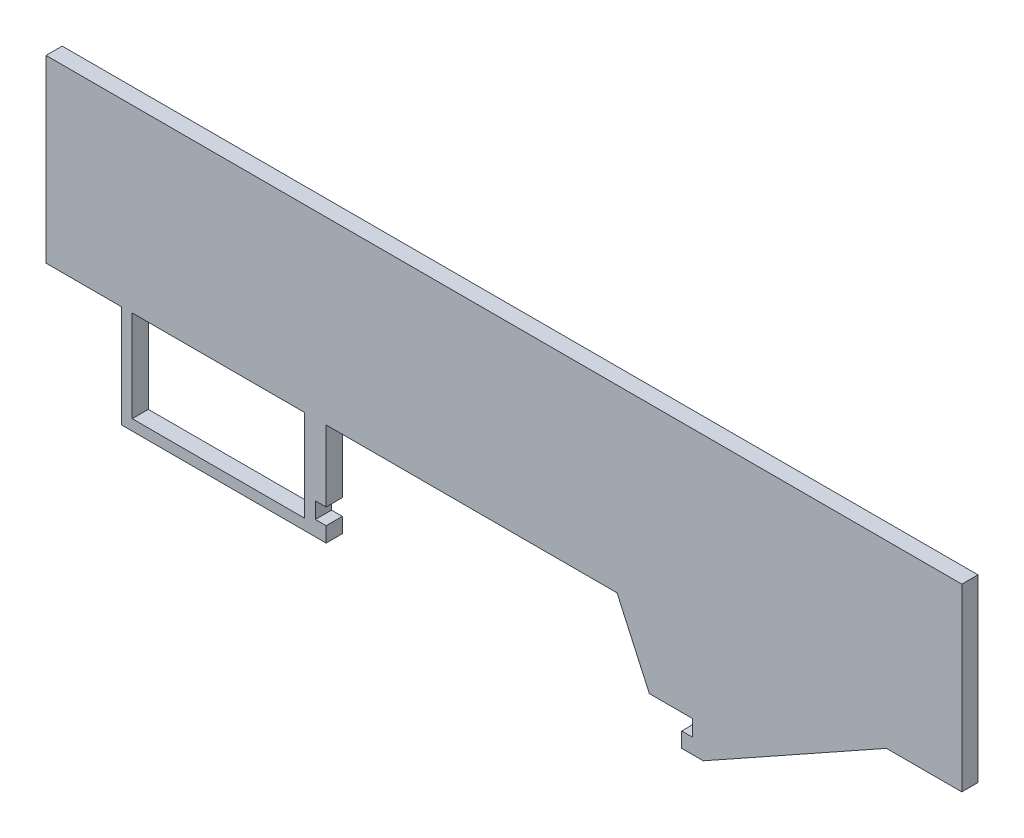
from build123d import *

# Parameters (mm, degrees)
SKETCH1_W           = 16
SKETCH1_H           = 8.5
BOSS_EXTRUDE1_DEPTH = 1.5


with BuildPart() as part:
    # Sketch1 → Boss-Extrude1 (new body)
    with BuildSketch(Plane.XY):
        Polygon((-42.5, 23.3), (42.5, 23.3), (42.5, 6.6), (35.5, 6.6), (18.5, -2.9), (16.5, -2.9), (16.5, -1.5), (17.5, -1.5), (17.5, 0), (13.5, 0), (10.5, 6.6), (-16.5, 6.6), (-16.5, 0), (-17.5, 0), (-17.5, -1.5), (-16.5, -1.5), (-16.5, -2.9), (-35.5, -2.9), (-35.5, 6.6), (-42.5, 6.6), align=None)
        with Locations((-26.5, 2.35)):
            Rectangle(SKETCH1_W, SKETCH1_H, mode=Mode.SUBTRACT)
    extrude(amount=BOSS_EXTRUDE1_DEPTH)


solid = part.part
